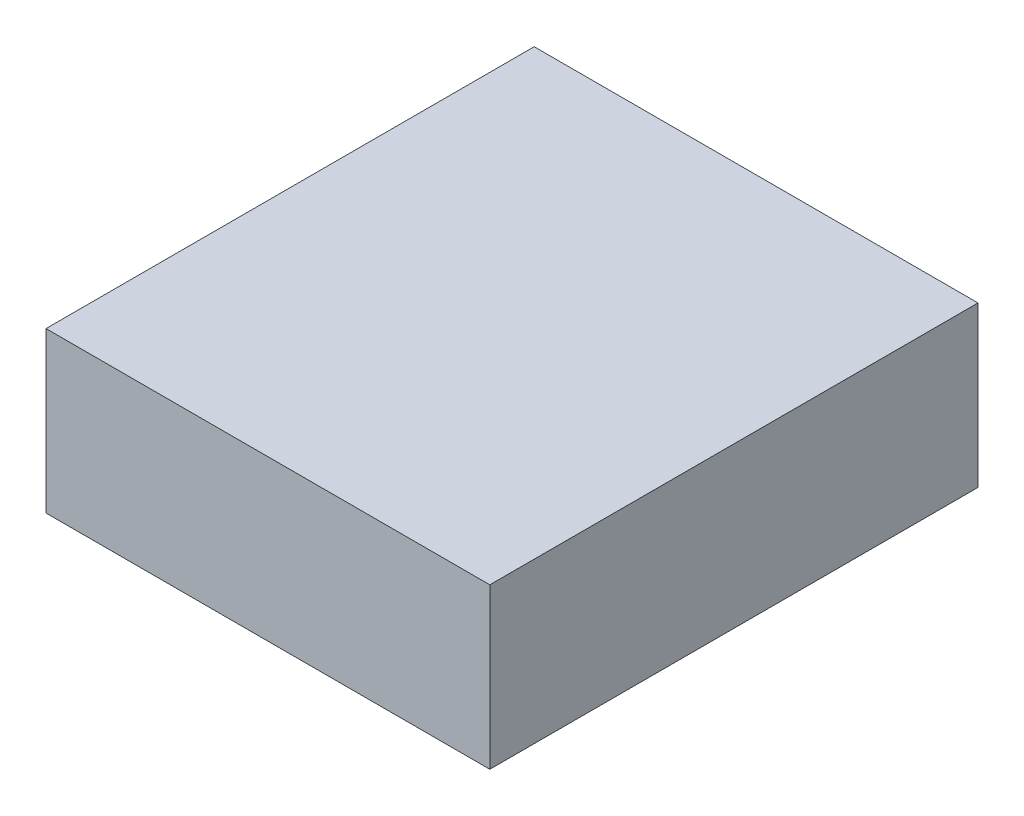
from build123d import *

# Parameters (mm, degrees)
SKETCH1_W           = 25000
SKETCH1_H           = 27500
BOSS_EXTRUDE1_DEPTH = 4500


with BuildPart() as part:
    # Sketch1 → Boss-Extrude1 (new body, symmetric)
    with BuildSketch(Plane(origin=(0, 0, 0), x_dir=(1, 0, 0), z_dir=(0, 1, 0))):
        Rectangle(SKETCH1_W, SKETCH1_H)
    extrude(amount=BOSS_EXTRUDE1_DEPTH, both=True)


solid = part.part
